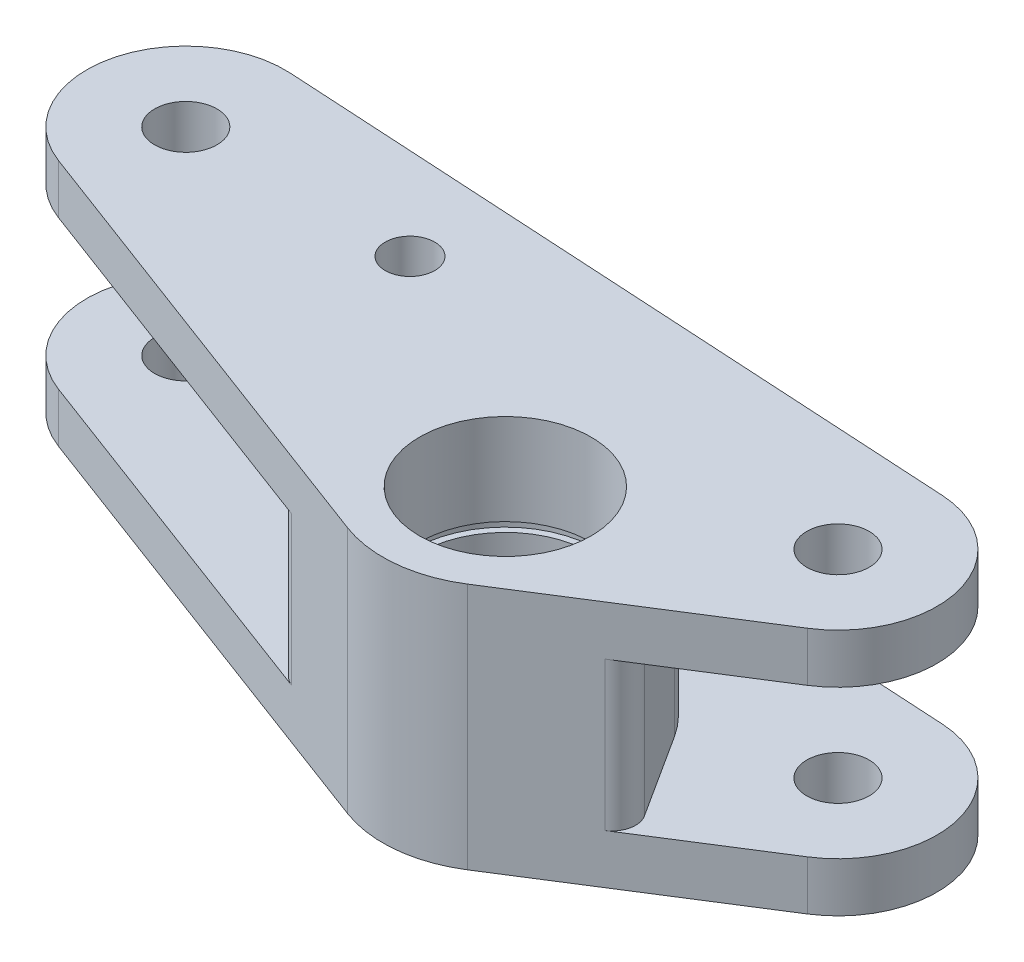
from build123d import *

# Parameters (mm, degrees)
SKETCH2_R           = 9
SKETCH2_R_2         = 4
SKETCH2_R_3         = 3.175
BOSS_EXTRUDE1_DEPTH = 31.75
CUT_EXTRUDE7_DEPTH  = 19.05
SKETCH4_R           = 11
CUT_EXTRUDE8_DEPTH  = 18.875
SKETCH5_R           = 11.825
CUT_EXTRUDE9_DEPTH  = 1.2


with BuildPart() as part:
    # Sketch2 → Boss-Extrude1 (new body)
    with BuildSketch(Plane(origin=(0, 0, 0), x_dir=(1, 0, 0), z_dir=(0, 1, 0))):
        with BuildLine():
            Line((16.780050899, 23.273406552), (76.169078327, 0.999356152))
            ThreePointArc((76.169078327, 0.999356152), (83.295947219, 0.081549283), (90.085976392, 2.43317287))
            Line((90.085976392, 2.43317287), (116.795312979, 19.333283493))
            ThreePointArc((116.795312979, 19.333283493), (122.299175659, 33.248981014), (110.733053142, 42.744451083))
            Line((110.733053142, 42.744451083), (21.968243349, 47.843674862))
            ThreePointArc((21.968243349, 47.843674862), (8.8138749, 37.788419678), (16.780050899, 23.273406552))
        make_face()
        with Locations((81.685914874, 15.708829783)):
            Circle(SKETCH2_R, mode=Mode.SUBTRACT)
        with Locations((110.004683999, 30.065354964)):
            Circle(SKETCH2_R_2, mode=Mode.SUBTRACT)
        with Locations((21.239874206, 35.164578743)):
            Circle(SKETCH2_R_2, mode=Mode.SUBTRACT)
        with Locations((50, 35.164578743)):
            Circle(SKETCH2_R_3, mode=Mode.SUBTRACT)
    extrude(amount=-BOSS_EXTRUDE1_DEPTH)

    # Sketch3 → Cut-Extrude7 (cut)
    with BuildSketch(Plane(origin=(0, -6.35, 0), x_dir=(1, 0, 0), z_dir=(0, 1, 0))):
        with BuildLine():
            Line((94.910034212, 24.187626921), (101.811056049, 13.424315235))
            ThreePointArc((101.811056049, 13.424315235), (102.214392091, 11.155436631), (100.889566337, 9.269879207))
            Line((100.889566337, 9.269879207), (124.896489339, 9.269879207))
            Line((124.896489339, 9.269879207), (123.850468237, 47.864578743))
            Line((123.850468237, 47.864578743), (8.539874206, 47.864578743))
            Line((8.539874206, 47.864578743), (8.539874206, 20.980420685))
            Line((8.539874206, 20.980420685), (64.646726928, 5.321032632))
            ThreePointArc((64.646726928, 5.321032632), (63.234252728, 6.421229435), (62.7, 8.130056632))
            Line((62.7, 8.130056632), (62.7, 18.708063959))
            ThreePointArc((62.7, 18.708063959), (62.972728913, 19.95786091), (63.741328279, 20.980420685))
            Line((63.741328279, 20.980420685), (71.429767985, 27.607518121))
            ThreePointArc((71.429767985, 27.607518121), (83.950010515, 31.253642555), (94.910034212, 24.187626921))
        make_face()
    extrude(amount=-CUT_EXTRUDE7_DEPTH, mode=Mode.SUBTRACT)

    # Sketch4 → Cut-Extrude8 (cut)
    with BuildSketch(Plane(origin=(0, 0, 0), x_dir=(1, 0, 0), z_dir=(0, 1, 0))):
        with Locations((81.685914874, 15.708829783)):
            Circle(SKETCH4_R)
    extrude(amount=-CUT_EXTRUDE8_DEPTH, mode=Mode.SUBTRACT)

    # Sketch5 → Cut-Extrude9 (cut)
    with BuildSketch(Plane(origin=(0, -12.875, 0), x_dir=(1, 0, 0), z_dir=(0, 1, 0))):
        with Locations((81.685914874, 15.708829783)):
            Circle(SKETCH5_R)
    extrude(amount=CUT_EXTRUDE9_DEPTH, mode=Mode.SUBTRACT)


solid = part.part
